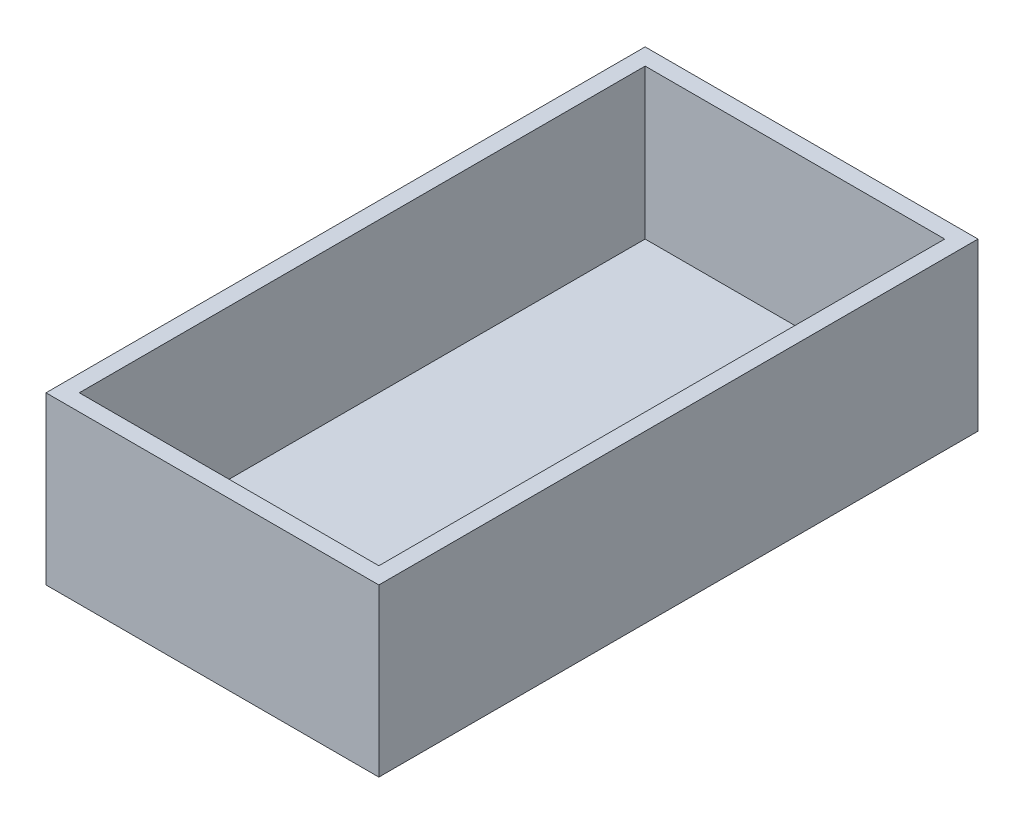
from build123d import *

# Parameters (mm, degrees)
SKETCH1_W           = 40
SKETCH1_H           = 72
BOSS_EXTRUDE1_DEPTH = 20
SHELL1_T            = -2


with BuildPart() as part:
    # Sketch1 → Boss-Extrude1 (new body)
    with BuildSketch(Plane(origin=(0, 0, 0), x_dir=(1, 0, 0), z_dir=(0, 1, 0))):
        Rectangle(SKETCH1_W, SKETCH1_H)
    extrude(amount=BOSS_EXTRUDE1_DEPTH)

    # Shell1
    shell1_openings = [part.faces().sort_by_distance(p)[0] for p in [
        (0, 20, 0),
    ]]
    offset(amount=SHELL1_T, openings=shell1_openings, kind=Kind.INTERSECTION)


solid = part.part
